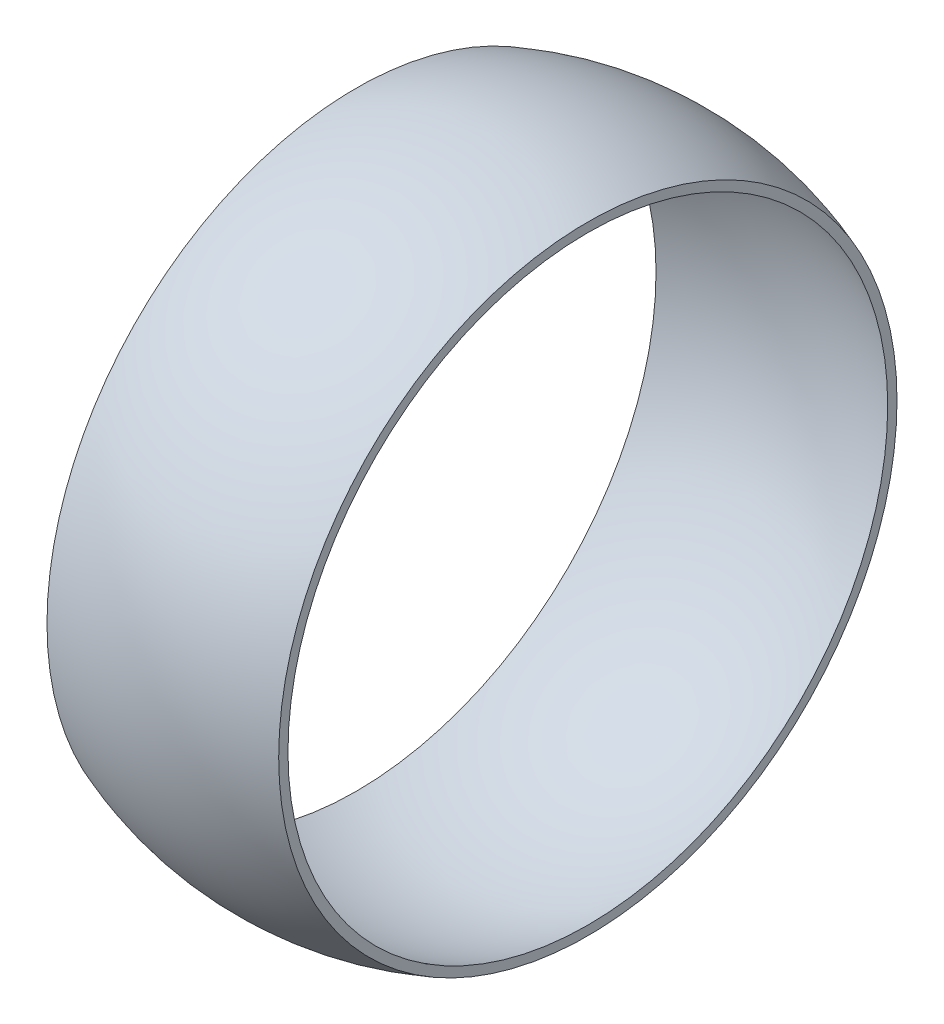
from build123d import *


with BuildPart() as part:
    # Sketch1 → Revolve1 (revolve)
    with BuildSketch(Plane.XY):
        with BuildLine():
            Line((-4, 10.675204916), (-4, 10.35422619))
            ThreePointArc((-4, 10.35422619), (0, 11.1), (4, 10.35422619))
            Line((4, 10.35422619), (4, 10.675204916))
            ThreePointArc((4, 10.675204916), (0, 11.4), (-4, 10.675204916))
        make_face()
    revolve(axis=Axis((0, 0, 0), (-1, 0, 0)))


solid = part.part
